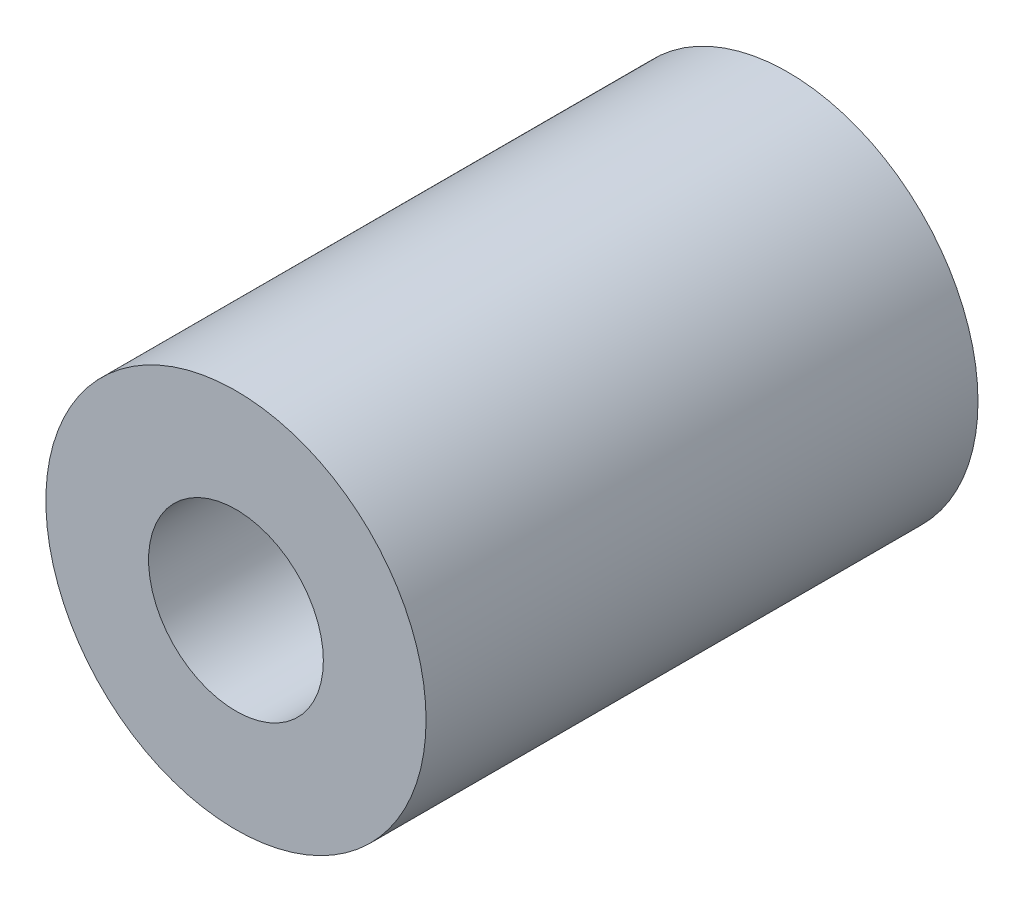
from build123d import *

# Parameters (mm, degrees)
SKETCH1_R           = 3.1
SKETCH1_R_2         = 1.425
BOSS_EXTRUDE1_DEPTH = 9


with BuildPart() as part:
    # Sketch1 → Boss-Extrude1 (new body)
    with BuildSketch(Plane.XY):
        Circle(SKETCH1_R)
        Circle(SKETCH1_R_2, mode=Mode.SUBTRACT)
    extrude(amount=BOSS_EXTRUDE1_DEPTH)


solid = part.part
